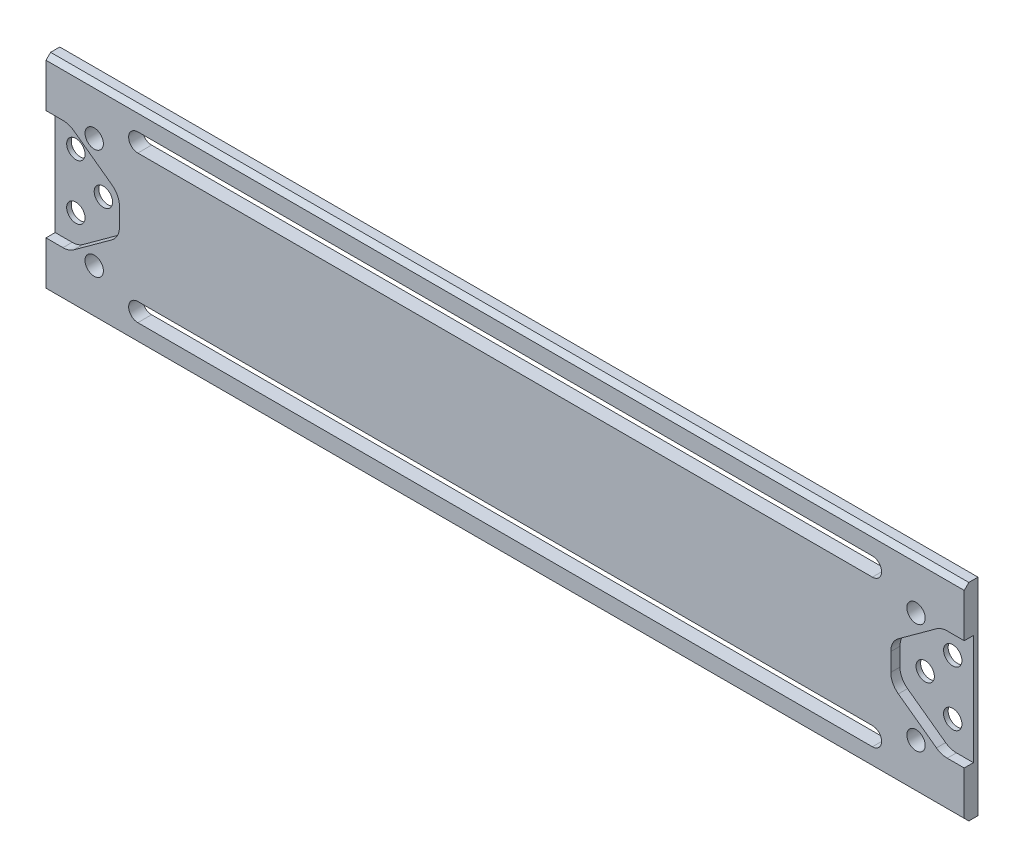
from build123d import *

# Parameters (mm, degrees)
SKETCH1_W            = 200
SKETCH1_H            = 45
BOSS_EXTRUDE1_DEPTH  = 3
SKETCH2_R            = 2
CUT_EXTRUDE1_DEPTH   = 5
CUT_EXTRUDE5_DEPTH   = 2
CHAMFER2_SIZE        = 1
FILLET1_R            = 4
FILLET1_OF_MIRROR4_R = 4
CUT_EXTRUDE6_DEPTH   = 10


with BuildPart() as part:
    # Sketch1 → Boss-Extrude1 (new body)
    with BuildSketch(Plane.XY):
        Rectangle(SKETCH1_W, SKETCH1_H)
    extrude(amount=BOSS_EXTRUDE1_DEPTH)

    # Sketch2 → Cut-Extrude1 (cut)
    with BuildSketch(Plane(origin=(0, 0, 0), x_dir=(-1, 0, 0), z_dir=(0, 0, -1))):
        with Locations((89.5, 0)):
            Circle(SKETCH2_R)
        with Locations((95.5, 6)):
            Circle(SKETCH2_R)
        with Locations((95.5, -6)):
            Circle(SKETCH2_R)
        with Locations((89.5, -12)):
            Circle(SKETCH2_R)
        with Locations((89.5, 12)):
            Circle(SKETCH2_R)
    cut_extrude1 = extrude(amount=-CUT_EXTRUDE1_DEPTH, mode=Mode.SUBTRACT)

    # Sketch8 → Cut-Extrude5 (cut)
    with BuildSketch(Plane.XY.offset(3)):
        Polygon((-84, 4), (-84, -4), (-95, -12), (-100, -12), (-100, 12), (-95, 12), align=None)
    cut_extrude5 = extrude(amount=-CUT_EXTRUDE5_DEPTH, mode=Mode.SUBTRACT)

    # Chamfer2
    chamfer2_edges = [part.edges().sort_by_distance(p)[0] for p in [
        (0, -22.5, 3),
        (0, 22.5, 3),
    ]]
    chamfer(chamfer2_edges, length=CHAMFER2_SIZE)

    # Fillet1
    fillet1_edges = [part.edges().sort_by_distance(p)[0] for p in [
        (-95, 12, 2),
        (-84, 4, 2),
        (-84, -4, 2),
        (-95, -12, 2),
    ]]
    fillet(fillet1_edges, radius=FILLET1_R)

    # Mirror4: Cut-Extrude1, Cut-Extrude5 across plane
    add(cut_extrude1.mirror(Plane(origin=(0, 0, 0), x_dir=(0, 0, 1), z_dir=(1, 0, 0))), mode=Mode.SUBTRACT)
    add(cut_extrude5.mirror(Plane(origin=(0, 0, 0), x_dir=(0, 0, 1), z_dir=(1, 0, 0))), mode=Mode.SUBTRACT)

    # Fillet1 of Mirror4
    fillet1_of_mirror4_edges = [part.edges().sort_by_distance(p)[0] for p in [
        (95, 12, 2),
        (84, 4, 2),
        (84, -4, 2),
        (95, -12, 2),
    ]]
    fillet(fillet1_of_mirror4_edges, radius=FILLET1_OF_MIRROR4_R)

    # Sketch9 → Cut-Extrude6 (cut)
    with BuildSketch(Plane.XY.offset(3)):
        with BuildLine():
            Line((80, -18), (-80, -18))
            ThreePointArc((-80, -18), (-82, -16), (-80, -14))
            Line((-80, -14), (80, -14))
            ThreePointArc((80, -14), (82, -16), (80, -18))
        make_face()
    cut_extrude6 = extrude(amount=-CUT_EXTRUDE6_DEPTH, mode=Mode.SUBTRACT)

    # Mirror5: Cut-Extrude6 across plane
    add(cut_extrude6.mirror(Plane.ZX), mode=Mode.SUBTRACT)


solid = part.part
